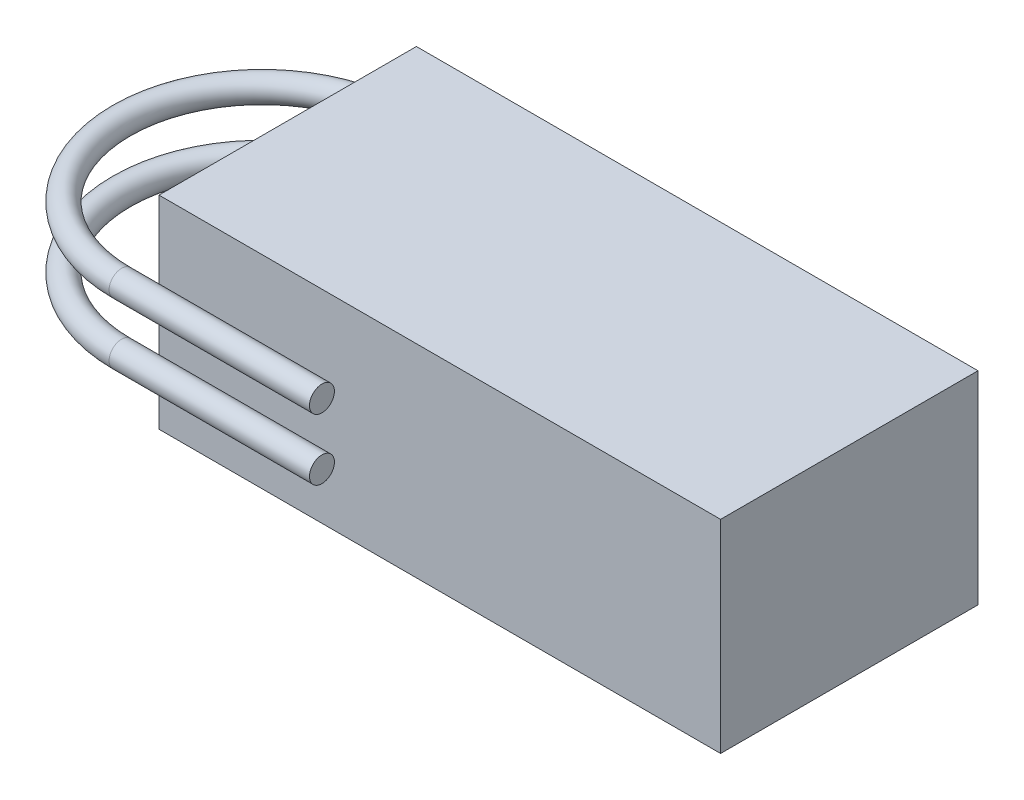
from build123d import *

# Parameters (mm, degrees)
ESQUISSE1_W          = 72
ESQUISSE1_H          = 33
BOSS_EXTRU_1_DEPTH   = 26
ESQUISSE3_R          = 1.6
BOSS_EXTRU_2_DEPTH   = 25.689186
BOSS_EXTRU_2_2_DEPTH = 25.689186
ESQUISSE4_R          = 1.6
R_VOLUTION1_ANGLE    = 180


with BuildPart() as part:
    # Esquisse1 → Boss.-Extru.1 (new body)
    with BuildSketch(Plane(origin=(0, 0, 0), x_dir=(1, 0, 0), z_dir=(0, 1, 0))):
        Rectangle(ESQUISSE1_W, ESQUISSE1_H)
    extrude(amount=BOSS_EXTRU_1_DEPTH)



with BuildPart() as body_2:
    # Esquisse3 → Boss.-Extru.2 (new body)
    with BuildSketch(Plane.ZY.offset(10.310814339)):
        with Locations((21.300154865, 18.67433682)):
            Circle(ESQUISSE3_R)
    extrude(amount=BOSS_EXTRU_2_DEPTH)


with BuildPart() as body_3:
    # Esquisse3 → Boss.-Extru.2 2 (new body)
    with BuildSketch(Plane.ZY.offset(10.310814339)):
        with Locations((21.300154865, 10.80733682)):
            Circle(ESQUISSE3_R)
    extrude(amount=BOSS_EXTRU_2_2_DEPTH)


with BuildPart() as part_1:
    add(part.part)

    add(body_2.part)  # Révolution1 merges body 2

    add(body_3.part)  # Révolution1 merges body 3
    # Esquisse4 → Révolution1 (revolve)
    with BuildSketch(Plane.ZY.offset(36)):
        with Locations((21.300154865, 18.67433682)):
            Circle(ESQUISSE4_R)
        with Locations((21.300154865, 10.80733682)):
            Circle(ESQUISSE4_R)
    revolve(axis=Axis((-36, 26, 3.300154865), (0, -1, 0)), revolution_arc=R_VOLUTION1_ANGLE)


solid = part_1.part
